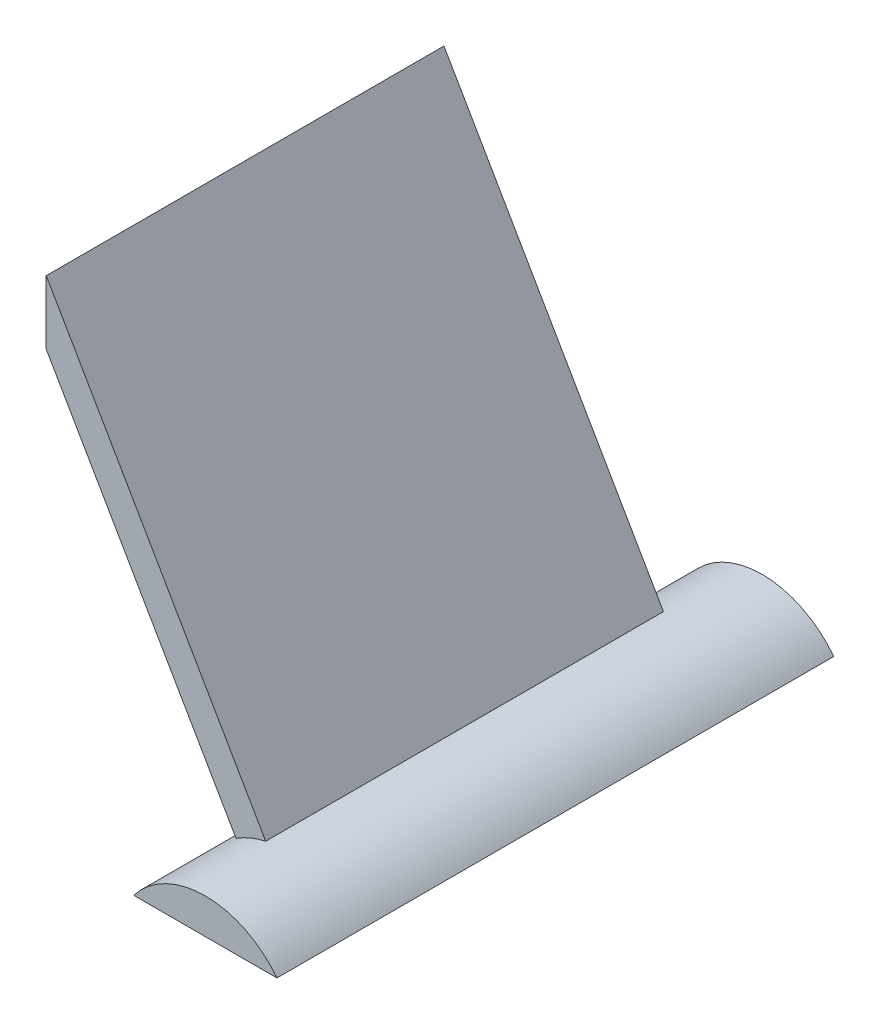
from build123d import *

# Parameters (mm, degrees)
BOSS_EXTRUDE1_DEPTH      = 88.9
BOSS_EXTRUDE2_DEPTH      = 31.75
BOSS_EXTRUDE2_DEPTH_BACK = 31.75


with BuildPart() as part:
    # Sketch2 → Boss-Extrude1 (new body)
    with BuildSketch(Plane.XY):
        with BuildLine():
            Line((90.17, 0), (67.31, 0))
            ThreePointArc((67.31, 0), (72.367383476, 4.152406467), (78.74, 5.6388))
            ThreePointArc((78.74, 5.6388), (85.112616524, 4.152406467), (90.17, 0))
        make_face()
    extrude(amount=-BOSS_EXTRUDE1_DEPTH)

    # Sketch3 → Boss-Extrude2 (add, two sides)
    with BuildSketch(Plane.XY.offset(-44.45)) as boss_extrude2_sk:
        with BuildLine():
            Line((40.64, 65.991135768), (75.674904681, 5.308900822))
            ThreePointArc((75.674904681, 5.308900822), (73.244625787, 4.48173949), (70.942491559, 3.345680792))
            Line((70.942491559, 3.345680792), (40.64, 55.831135768))
            Line((40.64, 55.831135768), (40.64, 65.991135768))
        make_face()
    extrude(amount=BOSS_EXTRUDE2_DEPTH)
    extrude(boss_extrude2_sk.sketch, amount=-BOSS_EXTRUDE2_DEPTH_BACK)


solid = part.part
